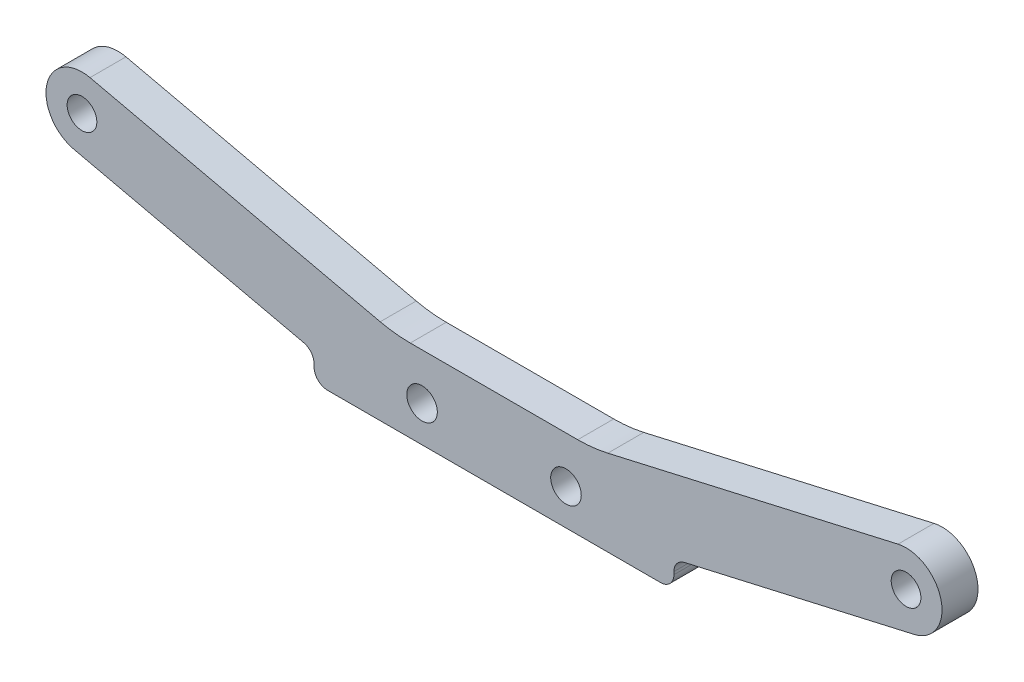
from build123d import *

# Parameters (mm, degrees)
SKETCH2_R             = 0.5
BASE_DEPTH            = 2
M3_CLEARANCE_HOLE1_D  = 3.4
M4X0_7_TAPPED_HOLE1_D = 3.3


with BuildPart() as part:
    # Sketch2 → Base (new body, symmetric)
    with BuildSketch(Plane.XY):
        with BuildLine():
            Line((-18.5, 0), (18.5, 0))
            ThreePointArc((18.5, 0), (19.560660172, 0.439339828), (20, 1.5))
            Line((20, 1.5), (20, 1.8041591))
            ThreePointArc((20, 1.8041591), (20.327112072, 2.739217337), (21.165778543, 3.266450459))
            Line((21.165778543, 3.266450459), (46.691257218, 9.100556377))
            ThreePointArc((46.691257218, 9.100556377), (49.699443623, 13.891257218), (44.908742782, 16.899443623))
            Line((44.908742782, 16.899443623), (12.649834838, 9.526344449))
            ThreePointArc((12.649834838, 9.526344449), (10.989330142, 9.243827753), (9.307620269, 9.149258036))
            Line((9.307620269, 9.149258036), (-9.307620269, 9.149258036))
            ThreePointArc((-9.307620269, 9.149258036), (-10.989330142, 9.243827753), (-12.649834838, 9.526344449))
            Line((-12.649834838, 9.526344449), (-44.908742782, 16.899443623))
            ThreePointArc((-44.908742782, 16.899443623), (-49.699443623, 13.891257218), (-46.691257218, 9.100556377))
            Line((-46.691257218, 9.100556377), (-21.165778543, 3.266450459))
            ThreePointArc((-21.165778543, 3.266450459), (-20.327112072, 2.739217337), (-20, 1.8041591))
            Line((-20, 1.8041591), (-20, 1.5))
            ThreePointArc((-20, 1.5), (-19.560660172, 0.439339828), (-18.5, 0))
        make_face()
        with Locations((-45.8, 13)):
            Circle(SKETCH2_R, mode=Mode.SUBTRACT)
        with Locations((-8, 4)):
            Circle(SKETCH2_R, mode=Mode.SUBTRACT)
        with Locations((8, 4)):
            Circle(SKETCH2_R, mode=Mode.SUBTRACT)
        with Locations((45.8, 13)):
            Circle(SKETCH2_R, mode=Mode.SUBTRACT)
    extrude(amount=BASE_DEPTH, both=True)

    # M3 Clearance Hole1 (through all)
    with Locations(Plane(origin=(0, 4, 2), x_dir=(1, 0, 0), z_dir=(0, 0, 1))):
        with Locations((-8, 0), (8, 0)):
            Hole(M3_CLEARANCE_HOLE1_D / 2)

    # M4x0.7 Tapped Hole1 (through all)
    with Locations(Plane(origin=(0, 0, 2), x_dir=(-1, 0, 0), z_dir=(0, 0, 1))):
        with Locations((-45.8, -13), (45.8, -13)):
            Hole(M4X0_7_TAPPED_HOLE1_D / 2)


solid = part.part
